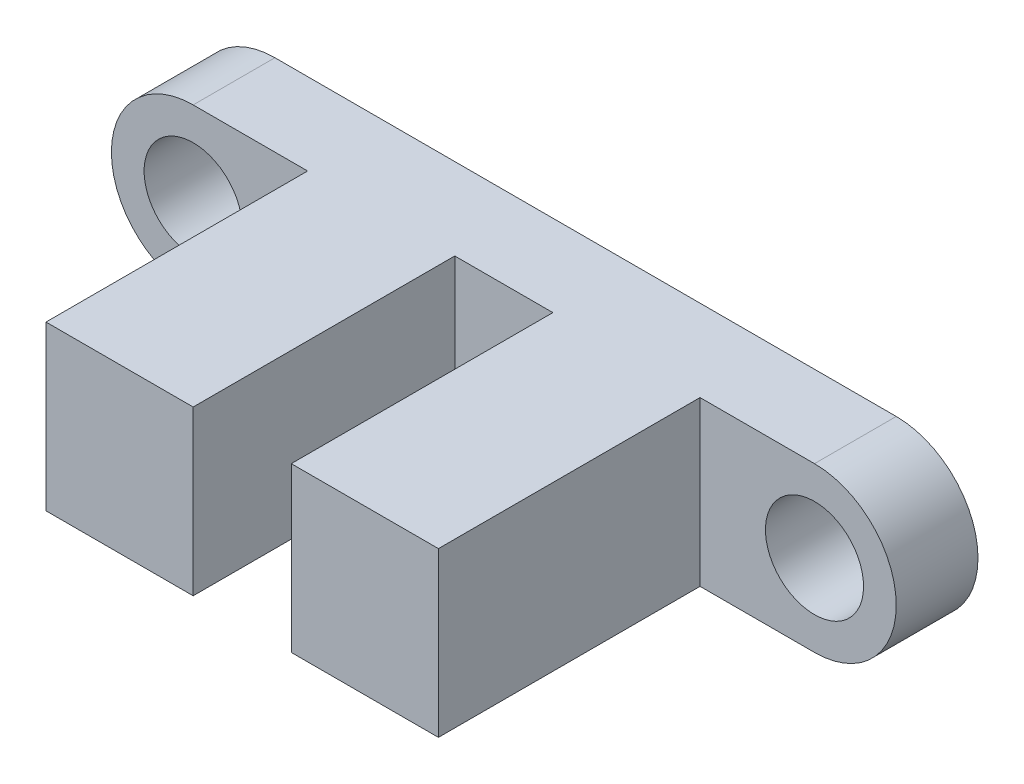
from build123d import *

# Parameters (mm, degrees)
SKETCH_1_R      = 1.5
EXTRUDE_1_DEPTH = 2.5
SKETCH_2_W      = 4.5
SKETCH_2_H      = 5
EXTRUDE_2_DEPTH = 8


with BuildPart() as part:
    # ｽｹｯﾁ1 → ﾎﾞｽ - 押し出し1 (new body)
    with BuildSketch(Plane.XY):
        with BuildLine():
            Line((0, 2.5), (19, 2.5))
            ThreePointArc((19, 2.5), (21.5, 0), (19, -2.5))
            Line((19, -2.5), (0, -2.5))
            ThreePointArc((0, -2.5), (-2.5, 0), (0, 2.5))
        make_face()
        Circle(SKETCH_1_R, mode=Mode.SUBTRACT)
        with Locations((19, 0)):
            Circle(SKETCH_1_R, mode=Mode.SUBTRACT)
    extrude(amount=EXTRUDE_1_DEPTH)

    # ｽｹｯﾁ2 → ﾎﾞｽ - 押し出し2 (add)
    with BuildSketch(Plane.XY.offset(2.5)):
        with Locations((5.75, 0)):
            Rectangle(SKETCH_2_W, SKETCH_2_H)
        with Locations((13.25, 0)):
            Rectangle(SKETCH_2_W, SKETCH_2_H)
    extrude(amount=EXTRUDE_2_DEPTH)


solid = part.part
